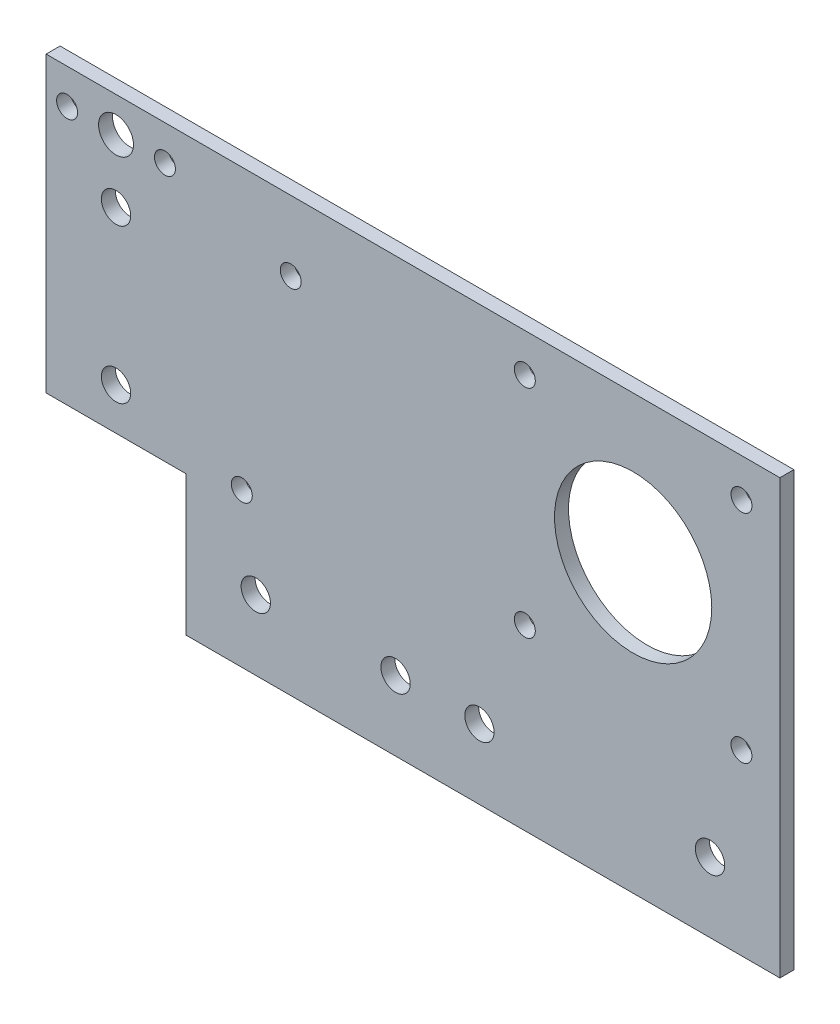
from build123d import *

# Parameters (mm, degrees)
SKETCH1_R           = 1.5
SKETCH1_R_2         = 11.25
SKETCH1_R_3         = 2.1
SKETCH1_R_4         = 2.5
BOSS_EXTRUDE1_DEPTH = 2


with BuildPart() as part:
    # Sketch1 → Boss-Extrude1 (new body)
    with BuildSketch(Plane.XY):
        Polygon((0, 0), (20, 0), (20, -20), (105, -20), (105, 42), (0, 42), align=None)
        with Locations((3, 37)):
            Circle(SKETCH1_R, mode=Mode.SUBTRACT)
        with Locations((17, 37)):
            Circle(SKETCH1_R, mode=Mode.SUBTRACT)
        with Locations((84, 21)):
            Circle(SKETCH1_R_2, mode=Mode.SUBTRACT)
        with Locations((99.5, 36.5)):
            Circle(SKETCH1_R, mode=Mode.SUBTRACT)
        with Locations((68.5, 36.5)):
            Circle(SKETCH1_R, mode=Mode.SUBTRACT)
        with Locations((68.5, 5.5)):
            Circle(SKETCH1_R, mode=Mode.SUBTRACT)
        with Locations((99.5, 5.5)):
            Circle(SKETCH1_R, mode=Mode.SUBTRACT)
        with Locations((35, 32)):
            Circle(SKETCH1_R, mode=Mode.SUBTRACT)
        with Locations((28, 2)):
            Circle(SKETCH1_R, mode=Mode.SUBTRACT)
        with Locations((10, 28)):
            Circle(SKETCH1_R_3, mode=Mode.SUBTRACT)
        with Locations((10, 6)):
            Circle(SKETCH1_R_3, mode=Mode.SUBTRACT)
        with Locations((30, -10)):
            Circle(SKETCH1_R_3, mode=Mode.SUBTRACT)
        with Locations((95, -10)):
            Circle(SKETCH1_R_3, mode=Mode.SUBTRACT)
        with Locations((10, 37)):
            Circle(SKETCH1_R_4, mode=Mode.SUBTRACT)
        with Locations((50, -10)):
            Circle(SKETCH1_R_3, mode=Mode.SUBTRACT)
        with Locations((62, -10)):
            Circle(SKETCH1_R_3, mode=Mode.SUBTRACT)
    extrude(amount=BOSS_EXTRUDE1_DEPTH)


solid = part.part
